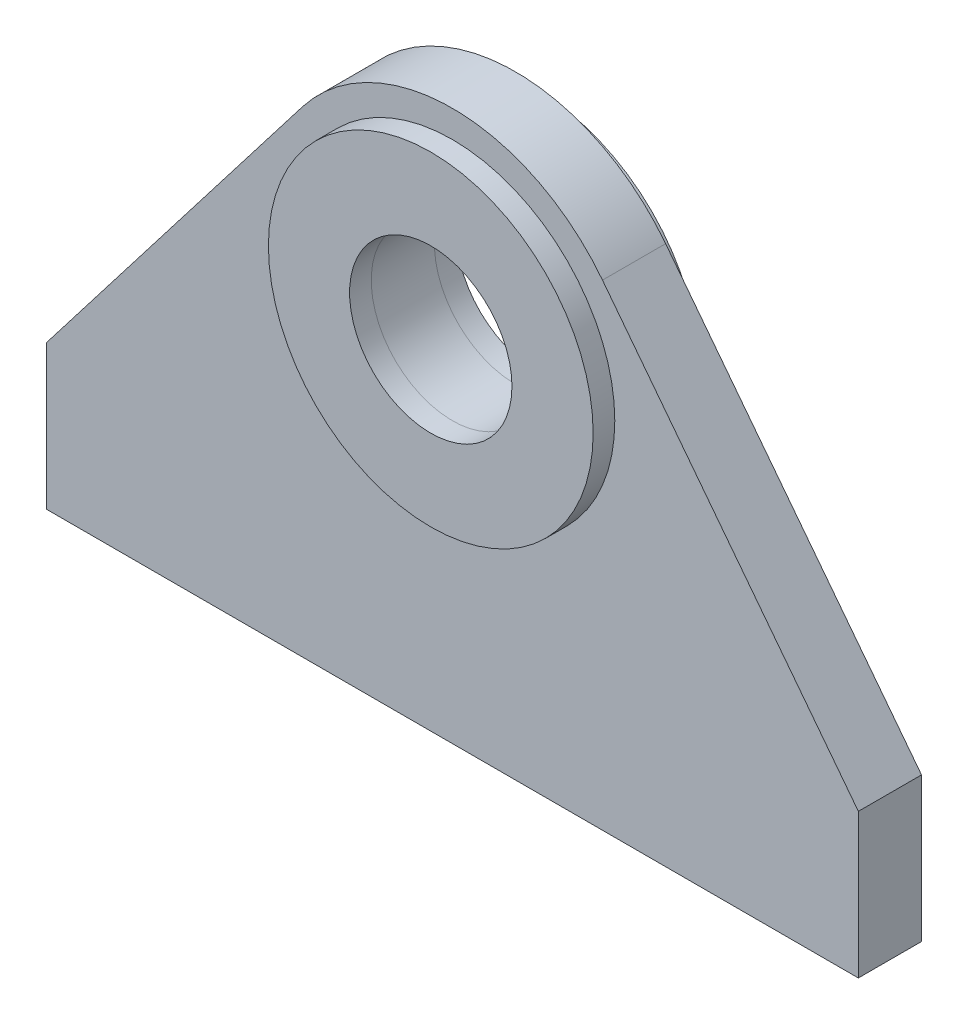
from build123d import *

# Parameters (mm, degrees)
SKETCH1_R           = 45
BOSS_EXTRUDE1_DEPTH = 17.5
SKETCH2_R           = 90
SKETCH2_R_2         = 45
BOSS_EXTRUDE2_DEPTH = 12


with BuildPart() as part:
    # Sketch1 → Boss-Extrude1 (new body, symmetric)
    with BuildSketch(Plane.XY):
        with BuildLine():
            Line((-225, 0), (225, 0))
            Line((225, 0), (225, 80))
            Line((225, 80), (83.177245824, 264.082335921))
            ThreePointArc((83.177245824, 264.082335921), (0, 305), (-83.177245824, 264.082335921))
            Line((-83.177245824, 264.082335921), (-225, 80))
            Line((-225, 80), (-225, 0))
        make_face()
        with Locations((0, 200)):
            Circle(SKETCH1_R, mode=Mode.SUBTRACT)
    extrude(amount=BOSS_EXTRUDE1_DEPTH, both=True)


with BuildPart() as body_2:
    # Sketch2 → Boss-Extrude2 (new body)
    with BuildSketch(Plane.XY.offset(17.5)):
        with Locations((0, 200)):
            Circle(SKETCH2_R)
        with Locations((0, 200)):
            Circle(SKETCH2_R_2, mode=Mode.SUBTRACT)
    extrude(amount=BOSS_EXTRUDE2_DEPTH)


with BuildPart() as body_3:
    # Mirror1: mirrored copy
    add(body_2.part.mirror(Plane.XY))


solid = Compound([part.part, body_2.part, body_3.part])
